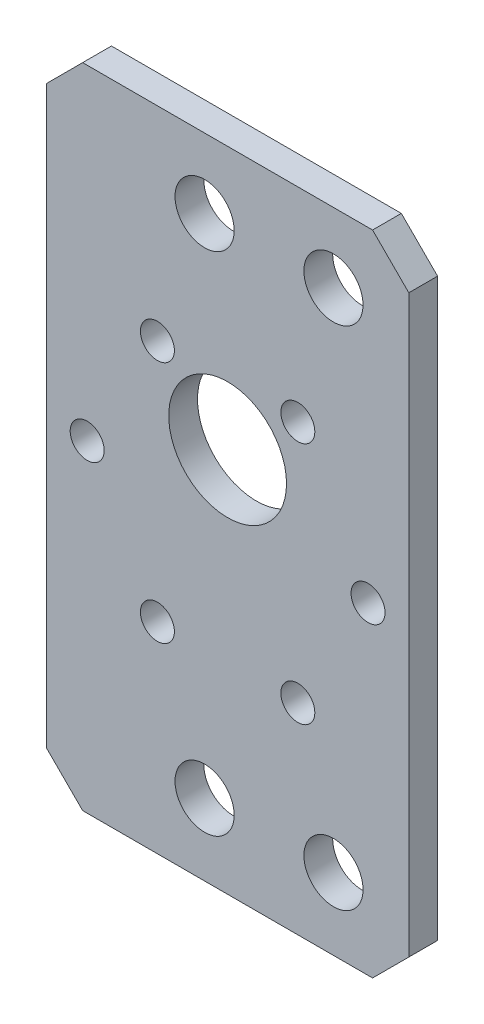
from build123d import *

# Parameters (mm, degrees)
SKETCH1_W               = 40
SKETCH1_H               = 71.5
SKETCH1_R               = 6.5
BOSS_EXTRUDE1_DEPTH     = 3.175
CHAMFER1_SIZE           = 4
SKETCH2_R               = 1.875
CUT_EXTRUDE1_DEPTH      = 48.07792078
F_1_4_CLEARANCE_HOLE1_D = 6.5278


with BuildPart() as part:
    # Sketch1 → Boss-Extrude1 (new body)
    with BuildSketch(Plane.XY):
        with Locations((0, -6.75)):
            Rectangle(SKETCH1_W, SKETCH1_H)
        Circle(SKETCH1_R, mode=Mode.SUBTRACT)
    extrude(amount=BOSS_EXTRUDE1_DEPTH)

    # Chamfer1
    chamfer1_edges = [part.edges().sort_by_distance(p)[0] for p in [
        (-20, 29, 1.5875),
        (20, 29, 1.5875),
        (-20, -42.5, 1.5875),
        (20, -42.5, 1.5875),
    ]]
    chamfer(chamfer1_edges, length=CHAMFER1_SIZE)

    # Sketch2 → Cut-Extrude1 (cut, through all)
    with BuildSketch(Plane.XY.offset(3.175)):
        with Locations((-7.75, 6.524250301)):
            Circle(SKETCH2_R)
        with Locations((7.75, 6.524250301)):
            Circle(SKETCH2_R)
        with Locations((15.5, -6.899143458)):
            Circle(SKETCH2_R)
        with Locations((7.75, -20.322537216)):
            Circle(SKETCH2_R)
        with Locations((-7.75, -20.322537216)):
            Circle(SKETCH2_R)
        with Locations((-15.5, -6.899143458)):
            Circle(SKETCH2_R)
    extrude(amount=-CUT_EXTRUDE1_DEPTH, mode=Mode.SUBTRACT)

    # 1_4 Clearance Hole1 (through all)
    with Locations(Plane(origin=(0, 0, 0), x_dir=(-1, 0, 0), z_dir=(0, 0, -1))):
        with Locations((-11.684, 21.299580024), (2.54, 21.299580024), (-11.684, -34.580419976), (2.54, -34.580419976)):
            Hole(F_1_4_CLEARANCE_HOLE1_D / 2)


solid = part.part
